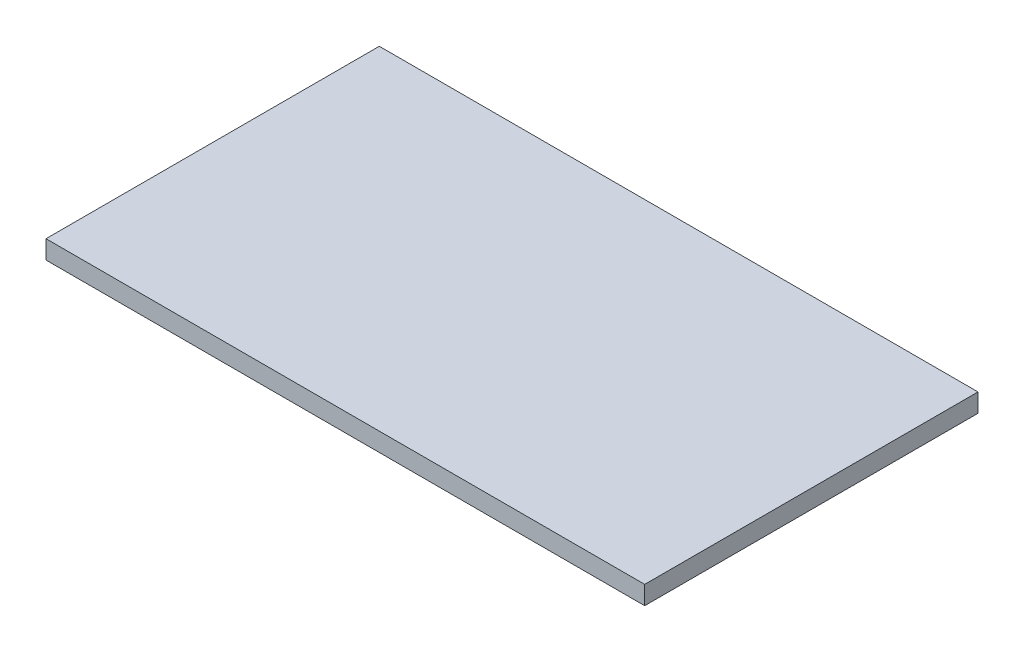
from build123d import *

# Parameters (mm, degrees)
ESBO_O1_W                = 4850
ESBO_O1_H                = 150
RESSALTO_EXTRUS_O1_DEPTH = 2700


with BuildPart() as part:
    # Esboço1 → Ressalto-extrusão1 (new body)
    with BuildSketch(Plane.XY):
        with Locations((2425, 75)):
            Rectangle(ESBO_O1_W, ESBO_O1_H)
    extrude(amount=RESSALTO_EXTRUS_O1_DEPTH)


solid = part.part
